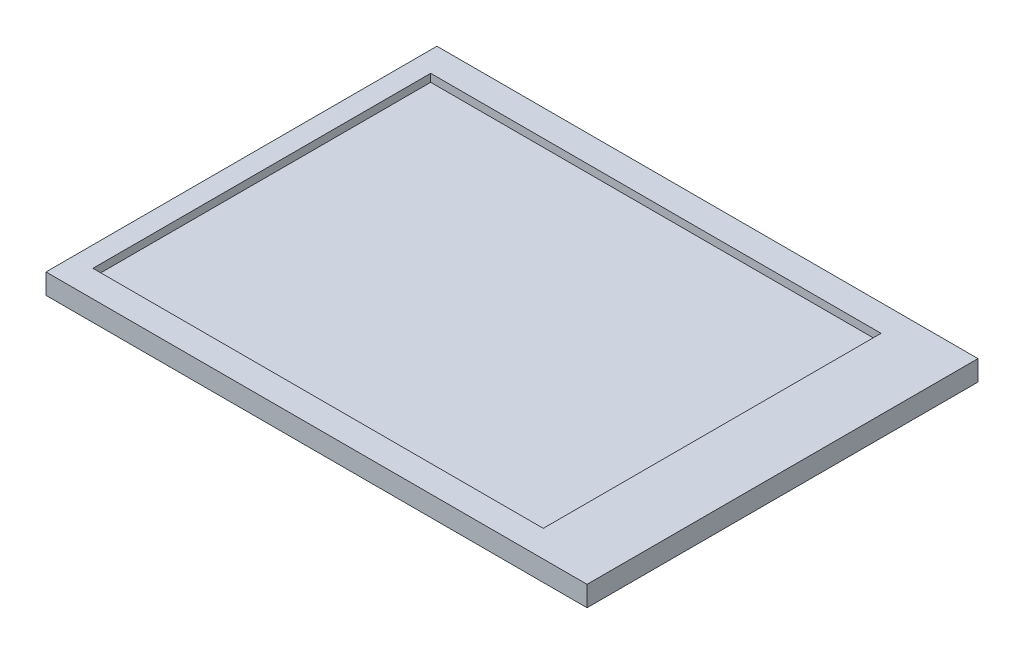
from build123d import *

# Parameters (mm, degrees)
LCD_W               = 69.2
LCD_H               = 50
EXTRUDE_2_DEPTH     = 2.6
LCD_3_W             = 57.6
LCD_3_H             = 43.2
CUT_EXTRUDE_1_DEPTH = 1


with BuildPart() as part:
    # LCD外壳 → 凸台-拉伸2 (new body)
    with BuildSketch(Plane(origin=(0, 0, 0), x_dir=(1, 0, 0), z_dir=(0, 1, 0))):
        Rectangle(LCD_W, LCD_H)
    extrude(amount=-EXTRUDE_2_DEPTH)

    # LCD外壳<3> → 切除-拉伸1 (cut)
    with BuildSketch(Plane(origin=(0, 0, 0), x_dir=(1, 0, 0), z_dir=(0, 1, 0))):
        with Locations((-3.2, 0)):
            Rectangle(LCD_3_W, LCD_3_H)
    extrude(amount=-CUT_EXTRUDE_1_DEPTH, mode=Mode.SUBTRACT)


solid = part.part
